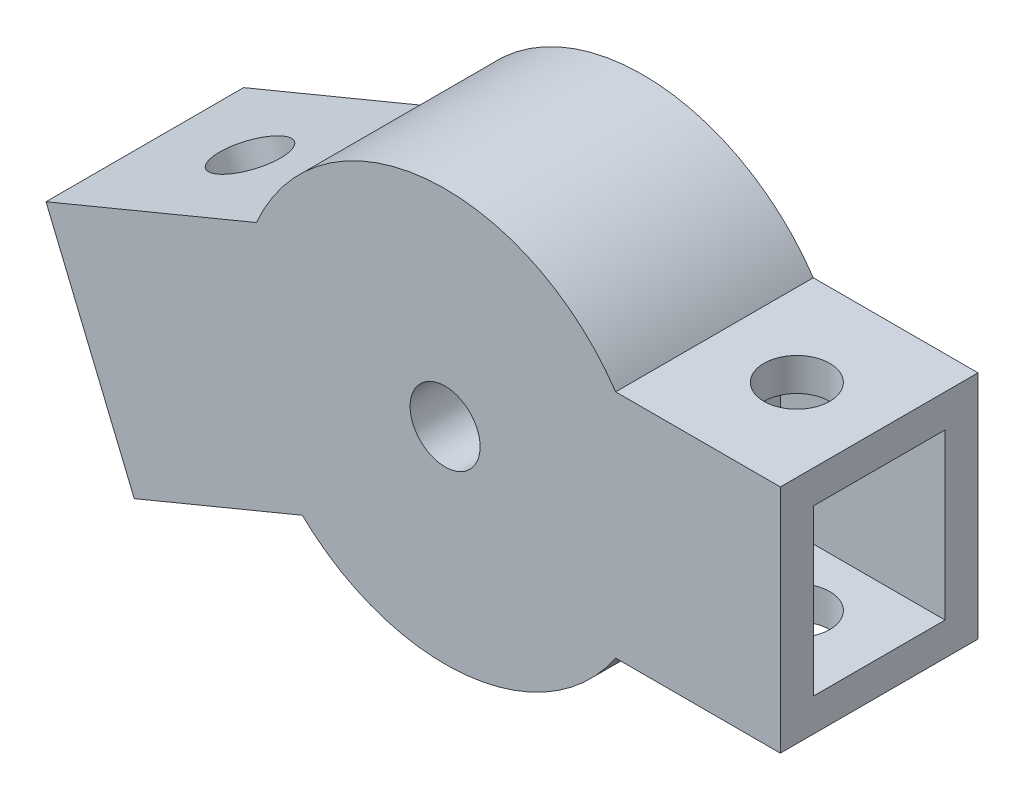
from build123d import *

# Parameters (mm, degrees)
SKETCH1_R           = 12.5
BOSS_EXTRUDE2_DEPTH = 12
CUT_EXTRUDE3_REACH  = 14
SKETCH5_R           = 2.125
BOSS_EXTRUDE3_DEPTH = 12
SKETCH9_W           = 8
SKETCH9_H           = 10
CUT_EXTRUDE4_DEPTH  = 10
SKETCH10_W          = 8
SKETCH10_H          = 10
CUT_EXTRUDE5_DEPTH  = 10
SKETCH11_R          = 2
CUT_EXTRUDE6_DEPTH  = 21.229774891
SKETCH12_R          = 2
CUT_EXTRUDE7_DEPTH  = 30.012682497


with BuildPart() as part:
    # Sketch1 → Boss-Extrude2 (new body)
    with BuildSketch(Plane.XY):
        Circle(SKETCH1_R)
    extrude(amount=BOSS_EXTRUDE2_DEPTH)

    # Sketch5 → Cut-Extrude3 (cut, up to next)
    with BuildSketch(Plane.XY.offset(12), mode=Mode.PRIVATE) as cut_extrude3_sk1:
        Circle(SKETCH5_R)
    cut_extrude3_tool1 = extrude(cut_extrude3_sk1.sketch, amount=-CUT_EXTRUDE3_REACH, mode=Mode.PRIVATE) & part.part
    add(cut_extrude3_tool1.solids().sort_by_distance((0, 0, 12))[0], mode=Mode.SUBTRACT)

    # Sketch6 → Boss-Extrude3 (add)
    with BuildSketch(Plane.XY):
        with BuildLine():
            Line((10.356157589, 7), (20.356157589, 7))
            Line((20.356157589, 7), (20.356157589, -7))
            Line((20.356157589, -7), (10.356157589, -7))
            ThreePointArc((10.356157589, -7), (12.5, 0), (10.356157589, 7))
        make_face()
        with BuildLine():
            Line((-24.231440373, -0.295461436), (-11.458506302, 4.995261088))
            ThreePointArc((-11.458506302, 4.995261088), (-12.259311424, -2.441164357), (-8.670952565, -9.003587153))
            Line((-8.670952565, -9.003587153), (-18.87387232, -13.229774891))
            Line((-18.87387232, -13.229774891), (-20.787289482, -8.610377228))
            Line((-20.787289482, -8.610377228), (-24.231440373, -0.295461436))
        make_face()
    extrude(amount=BOSS_EXTRUDE3_DEPTH)

    # Sketch9 → Cut-Extrude4 (cut)
    with BuildSketch(Plane(origin=(20.356157589, 0, 0), x_dir=(0, 0, -1), z_dir=(1, 0, 0))):
        with Locations((-6, 0)):
            Rectangle(SKETCH9_W, SKETCH9_H)
    extrude(amount=-CUT_EXTRUDE4_DEPTH, mode=Mode.SUBTRACT)

    # Sketch10 → Cut-Extrude5 (cut)
    with BuildSketch(Plane(origin=(-20.787289482, -8.610377228, 0), x_dir=(0, 0, 1), z_dir=(-0.923879533, -0.382683432, 0))):
        with Locations((6, 2)):
            Rectangle(SKETCH10_W, SKETCH10_H)
    extrude(amount=-CUT_EXTRUDE5_DEPTH, mode=Mode.SUBTRACT)

    # Sketch11 → Cut-Extrude6 (cut, through all)
    with BuildSketch(Plane(origin=(0, 7, 0), x_dir=(1, 0, 0), z_dir=(0, 1, 0))):
        with Locations((15.356157589, -6)):
            Circle(SKETCH11_R)
    extrude(amount=-CUT_EXTRUDE6_DEPTH, mode=Mode.SUBTRACT)

    # Sketch12 → Cut-Extrude7 (cut, through all)
    with BuildSketch(Plane(origin=(-3.444150891, 8.314915793, 0), x_dir=(0.923879533, 0.382683432, 0), z_dir=(-0.382683432, 0.923879533, 0))):
        with Locations((-15.587337893, -6)):
            Circle(SKETCH12_R)
    extrude(amount=-CUT_EXTRUDE7_DEPTH, mode=Mode.SUBTRACT)


solid = part.part
